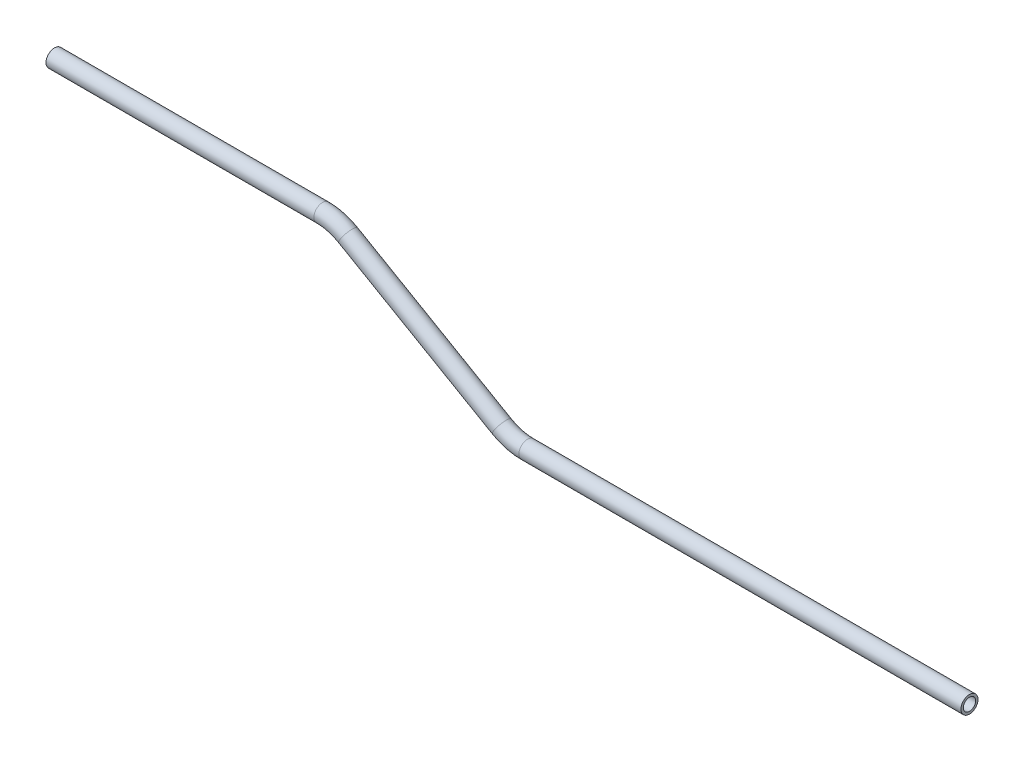
from build123d import *

# Parameters (mm, degrees)
SKETCH2_R   = 3.175
SKETCH2_R_2 = 2.286


with BuildPart() as part:
    # Sweep1: sweep along a path in Sketch1
    with BuildLine(Plane.XY) as sweep1_path:
        Line((-56.129783188, 3.074273142), (43.465854696, 3.074273142))
        ThreePointArc((43.465854696, 3.074273142), (48.396357506, 2.425160133), (52.990854696, 0.522057084))
        Line((52.990854696, 0.522057084), (110.140854696, -32.4735108))
        ThreePointArc((110.140854696, -32.4735108), (114.735351887, -34.376613849), (119.665854696, -35.025726858))
        Line((119.665854696, -35.025726858), (283.979422581, -35.025726858))
    # Sketch2 → Sweep1 (sweep)
    with BuildSketch(Plane(origin=(-56.129783188, 3.074273142, 0), x_dir=(0, 0, -1), z_dir=(1, 0, 0))):
        Circle(SKETCH2_R)
        Circle(SKETCH2_R_2, mode=Mode.SUBTRACT)
    sweep(path=sweep1_path.line)


solid = part.part
